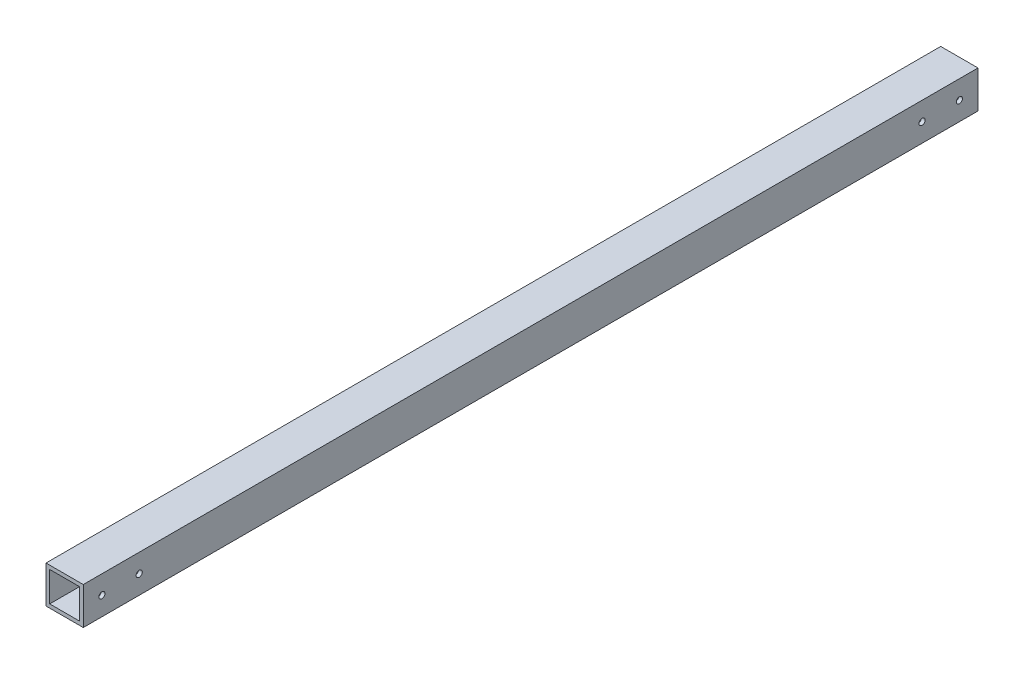
from build123d import *

# Parameters (mm, degrees)
SKETCH_1_W          = 20
SKETCH_1_H          = 20
SKETCH_1_W_2        = 16
SKETCH_1_H_2        = 16
EXTRUDE_1_DEPTH     = 560
SKETCH_3_R          = 2.2
CUT_EXTRUDE_2_DEPTH = 560
SKETCH_4_R          = 2.2
CUT_EXTRUDE_3_DEPTH = 560
SKETCH_5_W          = 35.553041162
SKETCH_5_H          = 54.410354854
CUT_EXTRUDE_4_DEPTH = 40
SKETCH_6_W          = 32.938502486
SKETCH_6_H          = 36.721798984
CUT_EXTRUDE_5_DEPTH = 40
SKETCH_8_R          = 1
CUT_EXTRUDE_7_DEPTH = 10
M4X0_7_1_D          = 3.3
M4X0_7_1_DEPTH      = 11.5
M4X0_7_1_TIP        = 0.991420021


with BuildPart() as part:
    # ｽｹｯﾁ1 → ﾎﾞｽ - 押し出し1 (new body)
    with BuildSketch(Plane.XY):
        Rectangle(SKETCH_1_W, SKETCH_1_H)
        Rectangle(SKETCH_1_W_2, SKETCH_1_H_2, mode=Mode.SUBTRACT)
    extrude(amount=EXTRUDE_1_DEPTH)

    # ｽｹｯﾁ3 → ｶｯﾄ - 押し出し2 (cut)
    with BuildSketch(Plane(origin=(10, 0, 0), x_dir=(0, 0, -1), z_dir=(1, 0, 0))):
        with Locations((-530, 0)):
            Circle(SKETCH_3_R)
        with Locations((-30, 0)):
            Circle(SKETCH_3_R)
    extrude(amount=-CUT_EXTRUDE_2_DEPTH, mode=Mode.SUBTRACT)

    # ｽｹｯﾁ4 → ｶｯﾄ - 押し出し3 (cut)
    with BuildSketch(Plane(origin=(0, 10, 0), x_dir=(1, 0, 0), z_dir=(0, 1, 0))):
        with Locations((0, -550)):
            Circle(SKETCH_4_R)
        with Locations((0, -10)):
            Circle(SKETCH_4_R)
    extrude(amount=-CUT_EXTRUDE_3_DEPTH, mode=Mode.SUBTRACT)

    # ｽｹｯﾁ5 → ｶｯﾄ - 押し出し4 (cut)
    with BuildSketch(Plane(origin=(0, 0, 0), x_dir=(-1, 0, 0), z_dir=(0, 0, -1))):
        Rectangle(SKETCH_5_W, SKETCH_5_H)
    extrude(amount=-CUT_EXTRUDE_4_DEPTH, mode=Mode.SUBTRACT)

    # ｽｹｯﾁ6 → ｶｯﾄ - 押し出し5 (cut)
    with BuildSketch(Plane.XY.offset(560)):
        Rectangle(SKETCH_6_W, SKETCH_6_H)
    extrude(amount=-CUT_EXTRUDE_5_DEPTH, mode=Mode.SUBTRACT)

    # ｽｹｯﾁ8 → ｶｯﾄ - 押し出し7 (cut)
    with BuildSketch(Plane(origin=(10, 0, 0), x_dir=(0, 0, -1), z_dir=(1, 0, 0))):
        with Locations((-50, 0)):
            Circle(SKETCH_8_R)
        with Locations((-70, 0)):
            Circle(SKETCH_8_R)
        with Locations((-490, 0)):
            Circle(SKETCH_8_R)
        with Locations((-510, 0)):
            Circle(SKETCH_8_R)
    extrude(amount=-CUT_EXTRUDE_7_DEPTH, mode=Mode.SUBTRACT)

    # M4x0.7 ねじ穴1
    with Locations(Plane(origin=(10, 0, 50), x_dir=(0, 0, 1), z_dir=(1, 0, 0))):
        with Locations((0, 0), (20, 0), (440, 0), (460, 0)):
            Hole(M4X0_7_1_D / 2, depth=M4X0_7_1_DEPTH)
            with Locations((0, 0, -(M4X0_7_1_DEPTH + M4X0_7_1_TIP / 2))):  # 118° drill point
                Cone(0, M4X0_7_1_D / 2, M4X0_7_1_TIP, mode=Mode.SUBTRACT)


solid = part.part
